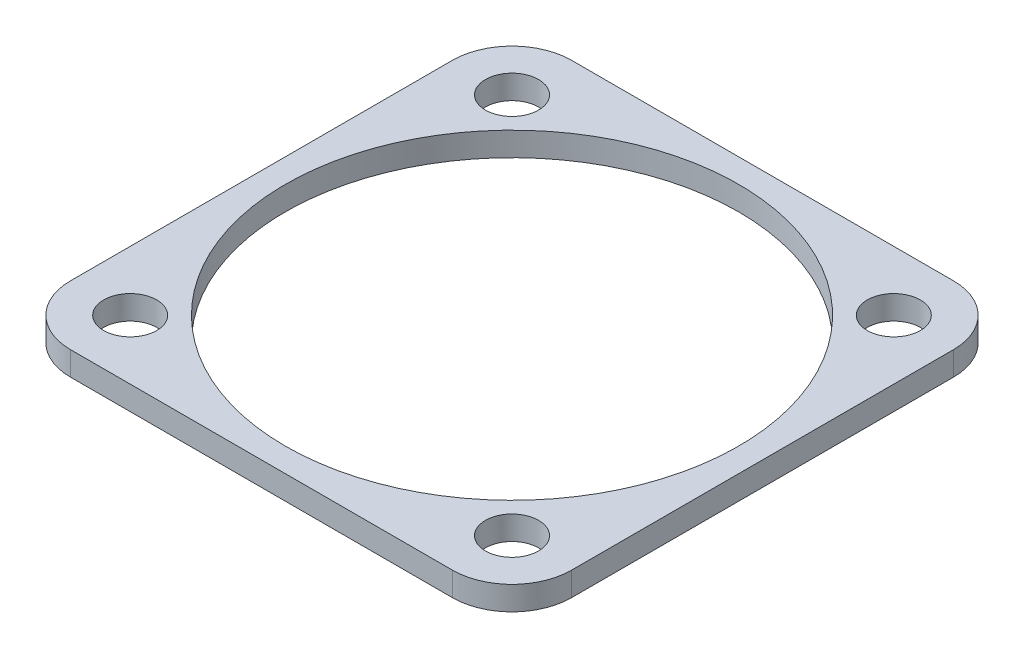
from build123d import *

# Parameters (mm, degrees)
SKETCH1_W           = 42
SKETCH1_H           = 42
BOSS_EXTRUDE1_DEPTH = 2
SKETCH2_R           = 2.225
SKETCH2_R_2         = 19
CUT_EXTRUDE1_DEPTH  = 2
FILLET1_R           = 5


with BuildPart() as part:
    # Sketch1 → Boss-Extrude1 (new body)
    with BuildSketch(Plane(origin=(0, 0, 0), x_dir=(1, 0, 0), z_dir=(0, 1, 0))):
        Rectangle(SKETCH1_W, SKETCH1_H)
    extrude(amount=BOSS_EXTRUDE1_DEPTH)

    # Sketch2 → Cut-Extrude1 (cut)
    with BuildSketch(Plane(origin=(0, 2, 0), x_dir=(1, 0, 0), z_dir=(0, 1, 0))):
        with Locations((-16, -16)):
            Circle(SKETCH2_R)
        with Locations((-16, 16)):
            Circle(SKETCH2_R)
        with Locations((16, 16)):
            Circle(SKETCH2_R)
        with Locations((16, -16)):
            Circle(SKETCH2_R)
        Circle(SKETCH2_R_2)
    extrude(amount=-CUT_EXTRUDE1_DEPTH, mode=Mode.SUBTRACT)

    # Fillet1
    fillet1_edges = [part.edges().sort_by_distance(p)[0] for p in [
        (-21, 1, 21),
        (-21, 1, -21),
        (21, 1, -21),
        (21, 1, 21),
    ]]
    fillet(fillet1_edges, radius=FILLET1_R)


solid = part.part
